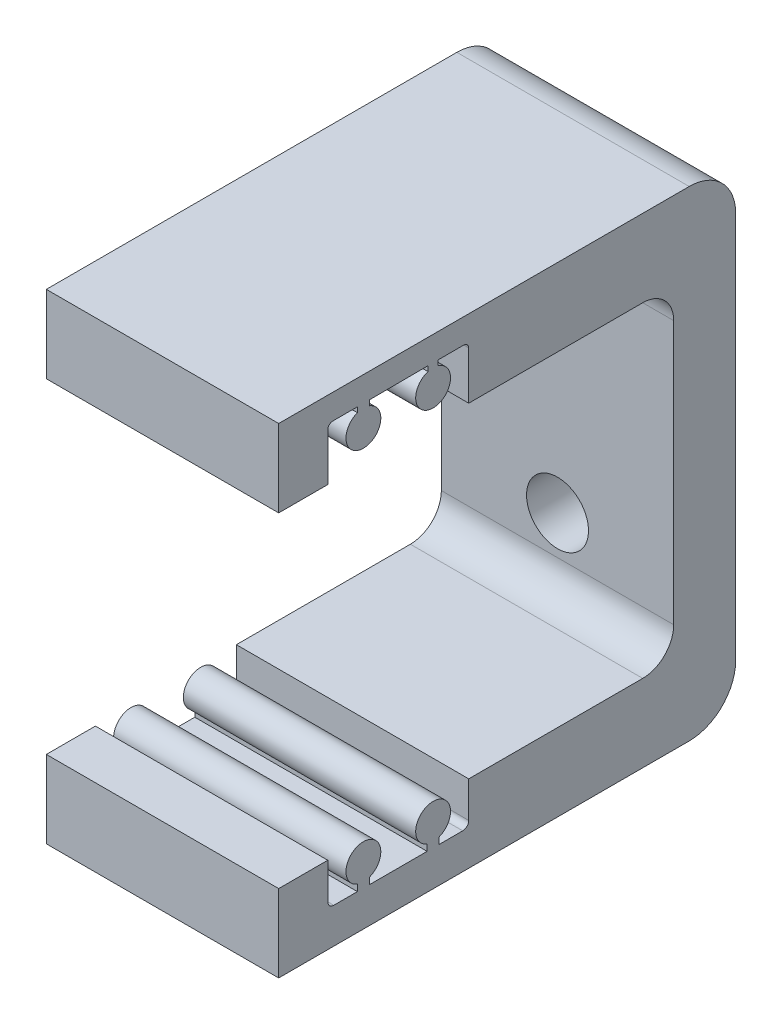
from build123d import *

# Parameters (mm, degrees)
ESBO_O1_W                  = 30
ESBO_O1_H                  = 10
RESSALTO_EXTRUS_O1_DEPTH   = 59
RESSALTO_EXTRUS_O1_2_DEPTH = 59
ESBO_O2_W                  = 30
ESBO_O2_H                  = 42
RESSALTO_EXTRUS_O2_DEPTH   = 8
CORTE_EXTRUS_O1_DEPTH      = 31
CORTE_EXTRUS_O2_DEPTH      = 4
FILETE1_R                  = 4
ESBO_O5_R                  = 4
CORTE_EXTRUS_O3_DEPTH      = 60
FILETE2_R                  = 6


with BuildPart() as part:
    # Esboço1 → Ressalto-extrusão1 (new body)
    with BuildSketch(Plane.XY):
        with Locations((0, 26)):
            Rectangle(ESBO_O1_W, ESBO_O1_H)
    extrude(amount=RESSALTO_EXTRUS_O1_DEPTH)



with BuildPart() as body_2:
    # Esboço1 → Ressalto-extrus_o1 2 (new body)
    with BuildSketch(Plane.XY):
        with Locations((0, -26)):
            Rectangle(ESBO_O1_W, ESBO_O1_H)
    extrude(amount=RESSALTO_EXTRUS_O1_2_DEPTH)


with BuildPart() as part_1:
    add(part.part)

    add(body_2.part)  # Ressalto-extrusão2 merges body 2
    # Esboço2 → Ressalto-extrusão2 (add)
    with BuildSketch(Plane(origin=(0, 0, 0), x_dir=(-1, 0, 0), z_dir=(0, 0, -1))):
        Rectangle(ESBO_O2_W, ESBO_O2_H)
    extrude(amount=-RESSALTO_EXTRUS_O2_DEPTH)

    # Esboço3 → Corte-extrusão1 (cut, through all)
    with BuildSketch(Plane.ZY.offset(15)):
        with BuildLine():
            Line((34.464319348, 27.180824333), (34.464319348, 21))
            Line((34.464319348, 21), (52.664319348, 21))
            Line((52.664319348, 21), (52.664319348, 27.13384671))
            ThreePointArc((52.664319348, 27.13384671), (52.473932816, 27.593480457), (52.014299068, 27.783866989))
            Line((52.014299068, 27.783866989), (48.83365389, 27.783866989))
            Line((48.83365389, 27.783866989), (48.853388433, 27.775806736))
            Line((48.853388433, 27.775806736), (48.83365389, 27.775908805))
            Line((48.83365389, 27.775908805), (48.83365389, 27.124623249))
            ThreePointArc((48.83365389, 27.124623249), (48.064319348, 22.760238146), (47.294984805, 27.124623249))
            Line((47.294984805, 27.124623249), (47.294984805, 27.783866989))
            Line((47.294984805, 27.783866989), (40.021105511, 27.821488377))
            Line((40.021105511, 27.821488377), (39.721105511, 27.821488377))
            Line((39.721105511, 27.821488377), (39.721105511, 27.162244637))
            ThreePointArc((39.721105511, 27.162244637), (39.064319348, 22.760238146), (38.407533184, 27.162244637))
            Line((38.407533184, 27.162244637), (38.407533184, 27.821488377))
            Line((38.407533184, 27.821488377), (35.104983392, 27.821488377))
            ThreePointArc((35.104983392, 27.821488377), (34.654639493, 27.631168232), (34.464319348, 27.180824333))
        make_face()
        with BuildLine():
            ThreePointArc((51.8897547, -26.423845407), (52.437454615, -26.196980674), (52.664319348, -25.649280759))
            Line((52.664319348, -25.649280759), (52.664319348, -20.77))
            Line((52.664319348, -20.77), (34.5, -20.77))
            Line((34.5, -20.77), (34.464319348, -20.770417185))
            Line((34.464319348, -20.770417185), (34.464319348, -25.649280759))
            ThreePointArc((34.464319348, -25.649280759), (34.69118408, -26.196980674), (35.238883995, -26.423845407))
            Line((35.238883995, -26.423845407), (38.294984805, -26.423845407))
            Line((38.294984805, -26.423845407), (38.294984805, -25.584623249))
            ThreePointArc((38.294984805, -25.584623249), (39.064319348, -21.220238146), (39.83365389, -25.584623249))
            Line((39.83365389, -25.584623249), (39.83365389, -26.423845407))
            Line((39.83365389, -26.423845407), (47.294984805, -26.423845407))
            Line((47.294984805, -26.423845407), (47.294984805, -25.584623249))
            ThreePointArc((47.294984805, -25.584623249), (48.064319348, -21.220238146), (48.83365389, -25.584623249))
            Line((48.83365389, -25.584623249), (48.83365389, -26.423845407))
            Line((48.83365389, -26.423845407), (51.8897547, -26.423845407))
        make_face()
    extrude(amount=-CORTE_EXTRUS_O1_DEPTH, mode=Mode.SUBTRACT)

    # Esboço4 → Corte-extrusão2 (cut)
    with BuildSketch(Plane.ZY.offset(15)):
        with BuildLine():
            Line((47.294984805, 27.783866989), (48.853388433, 27.775806736))
            Line((48.853388433, 27.775806736), (48.853388433, 27.117338044))
            ThreePointArc((48.853388433, 27.117338044), (48.055619332, 22.760254966), (47.291568671, 27.123377136))
            Line((47.291568671, 27.123377136), (47.294984805, 27.783866989))
        make_face()
        with BuildLine():
            Line((38.407533184, 27.821488377), (38.407533184, 27.162244637))
            ThreePointArc((38.407533184, 27.162244637), (39.064319348, 22.760238146), (39.721105511, 27.162244637))
            Line((39.721105511, 27.162244637), (39.721105511, 27.821488377))
            Line((39.721105511, 27.821488377), (38.407533184, 27.821488377))
        make_face()
    extrude(amount=-CORTE_EXTRUS_O2_DEPTH, mode=Mode.SUBTRACT)

    # Filete1
    filete1_edges = [part_1.edges().sort_by_distance(p)[0] for p in [
        (0, 21, 8),
        (0, -21, 8),
    ]]
    fillet(filete1_edges, radius=FILETE1_R)

    # Esboço5 → Corte-extrusão3 (cut, through all)
    with BuildSketch(Plane(origin=(0, 0, 0), x_dir=(-1, 0, 0), z_dir=(0, 0, -1))):
        with Locations((0, -12)):
            Circle(ESBO_O5_R)
        with Locations((0, 12)):
            Circle(ESBO_O5_R)
    extrude(amount=-CORTE_EXTRUS_O3_DEPTH, mode=Mode.SUBTRACT)

    # Filete2
    filete2_edges = [part_1.edges().sort_by_distance(p)[0] for p in [
        (0, -31, 0),
        (0, 31, 0),
    ]]
    fillet(filete2_edges, radius=FILETE2_R)


solid = part_1.part
